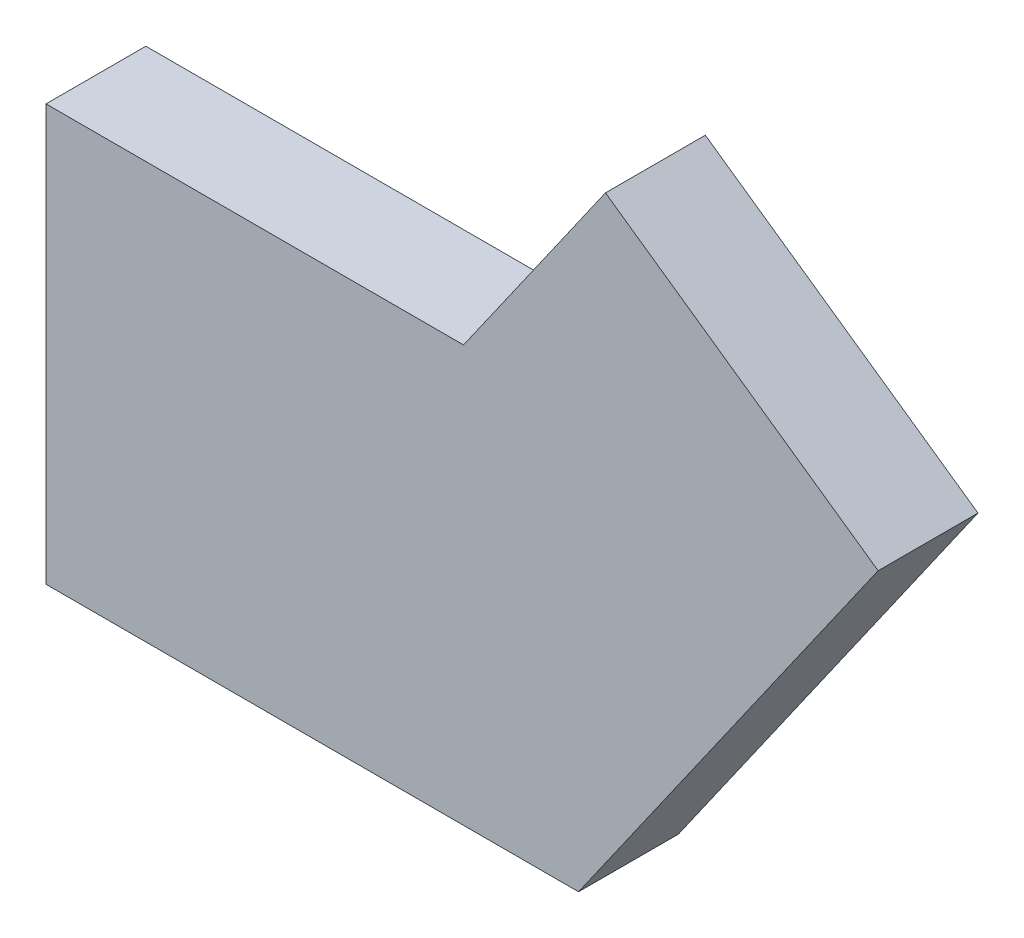
from build123d import *

# Parameters (mm, degrees)
BOSS_EXTRUDE1_DEPTH = 3


with BuildPart() as part:
    # Sketch1 → Boss-Extrude1 (new body, symmetric)
    with BuildSketch(Plane.XY):
        Polygon((-32, 0), (0, 0), (18, 25.706664121), (1.616959114, 37.178192848), (-6.91030332, 25), (-32, 25), align=None)
    extrude(amount=BOSS_EXTRUDE1_DEPTH, both=True)


solid = part.part
